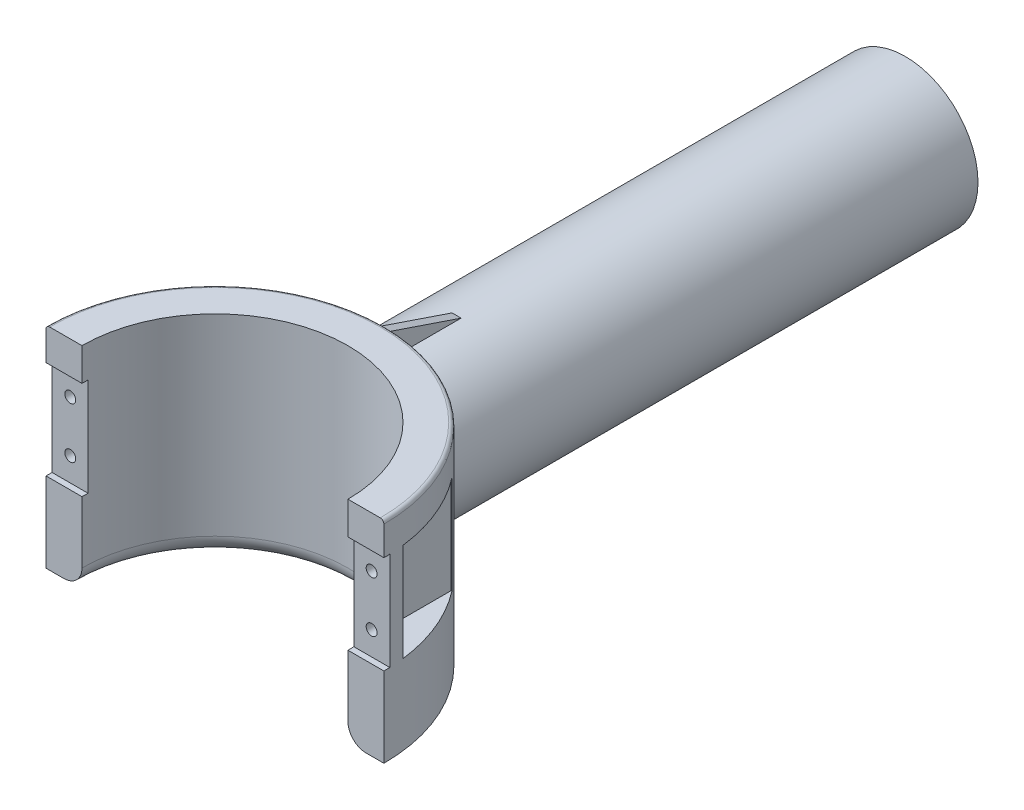
from build123d import *

# Parameters (mm, degrees)
EXTRUDE_1_DEPTH     = 58
FILLET_1_R          = 5
SKETCH_2_W          = 14.1984483
SKETCH_2_H          = 27
CUT_EXTRUDE_1_DEPTH = 1.65
CUT_EXTRUDE_START   = -22.111141
SKETCH_3_R          = 1.5
CUT_EXTRUDE_2_DEPTH = 22.111141
SKETCH_5_W          = 9.9
SKETCH_5_H          = 27
CUT_EXTRUDE_3_DEPTH = 22.65
SKETCH_7_R          = 20
EXTRUDE_2_DEPTH     = 150
CUT_EXTRUDE_START_2 = 15
SKETCH_9_W          = 36
SKETCH_9_H          = 32
CUT_EXTRUDE_5_DEPTH = 8
SKETCH_10_R         = 1
CUT_EXTRUDE_6_DEPTH = 2
FILLET_2_R          = 1
EXTRUDE_3_DEPTH     = 1.25


with BuildPart() as part:
    # 草图1 → 凸台-拉伸1 (new body)
    with BuildSketch(Plane(origin=(0, 0, 0), x_dir=(1, 0, 0), z_dir=(0, 1, 0))):
        with BuildLine():
            Line((-46.5, 0), (-36.6, 0))
            ThreePointArc((-36.6, 0), (0, 36.6), (36.6, 0))
            Line((36.6, 0), (46.5, 0))
            ThreePointArc((46.5, 0), (0, 46.5), (-46.5, 0))
        make_face()
    extrude(amount=EXTRUDE_1_DEPTH)

    # 圆角1
    fillet_1_edges = [part.edges().sort_by_distance(p)[0] for p in [
        (0, 0, -36.6),
    ]]
    fillet(fillet_1_edges, radius=FILLET_1_R)

    # 草图2 → 切除-拉伸1 (cut)
    with BuildSketch(Plane.XY):
        with Locations((-41.149885232, 35.5)):
            Rectangle(SKETCH_2_W, SKETCH_2_H)
    cut_extrude_1 = extrude(amount=-CUT_EXTRUDE_1_DEPTH, mode=Mode.SUBTRACT)

    # 草图3 → 切除-拉伸2 (cut)
    with BuildSketch(Plane.XY.offset(-1.65).offset(CUT_EXTRUDE_START)):
        with Locations((-41.470716586, 28.5)):
            Circle(SKETCH_3_R)
        with Locations((-41.470716586, 42.5)):
            Circle(SKETCH_3_R)
    cut_extrude_2 = extrude(amount=CUT_EXTRUDE_2_DEPTH, mode=Mode.SUBTRACT)

    # 草图5 → 切除-拉伸3 (cut)
    with BuildSketch(Plane.XY.offset(-5.65)):
        with Locations((-41.55, 35.5)):
            Rectangle(SKETCH_5_W, SKETCH_5_H)
    cut_extrude_3 = extrude(amount=-CUT_EXTRUDE_3_DEPTH, mode=Mode.SUBTRACT)

    # 镜向2: 切除-拉伸1, 切除-拉伸2, 切除-拉伸3 across plane
    add(cut_extrude_1.mirror(Plane(origin=(0, 0, 0), x_dir=(0, 0, 1), z_dir=(1, 0, 0))), mode=Mode.SUBTRACT)
    add(cut_extrude_2.mirror(Plane(origin=(0, 0, 0), x_dir=(0, 0, 1), z_dir=(1, 0, 0))), mode=Mode.SUBTRACT)
    add(cut_extrude_3.mirror(Plane(origin=(0, 0, 0), x_dir=(0, 0, 1), z_dir=(1, 0, 0))), mode=Mode.SUBTRACT)

    # 草图7 → 凸台-拉伸2 (add)
    with BuildSketch(Plane.XY.offset(-40)):
        with Locations((0, 30.227868372)):
            Circle(SKETCH_7_R)
    extrude(amount=-EXTRUDE_2_DEPTH)

    # 草图9 → 切除-拉伸5 (cut)
    with BuildSketch(Plane(origin=(0, 0, 0), x_dir=(1, 0, 0), z_dir=(0, 1, 0)).offset(CUT_EXTRUDE_START_2)):
        with Locations((0, 83.263825199)):
            Rectangle(SKETCH_9_W, SKETCH_9_H)
    extrude(amount=-CUT_EXTRUDE_5_DEPTH, mode=Mode.SUBTRACT)

    # 草图10 → 切除-拉伸6 (cut)
    with BuildSketch(Plane.XZ):
        with Locations((-26.156443727, -36.00125625)):
            Circle(SKETCH_10_R)
        with Locations((26.156443727, -36.00125625)):
            Circle(SKETCH_10_R)
    extrude(amount=-CUT_EXTRUDE_6_DEPTH, mode=Mode.SUBTRACT)

    # 圆角2
    fillet_2_edges = [part.edges().sort_by_distance(p)[0] for p in [
        (0, 58, -46.5),
    ]]
    fillet(fillet_2_edges, radius=FILLET_2_R)


with BuildPart() as body_2:
    # 草图11 → 凸台-拉伸3 (new body, symmetric)
    with BuildSketch(Plane(origin=(0, 0, 0), x_dir=(0, 0, -1), z_dir=(1, 0, 0))):
        Polygon((46.5, 50.227868372), (46.5, 57), (66.5, 50.227868372), align=None)
    extrude(amount=EXTRUDE_3_DEPTH, both=True)


solid = Compound([part.part, body_2.part])
